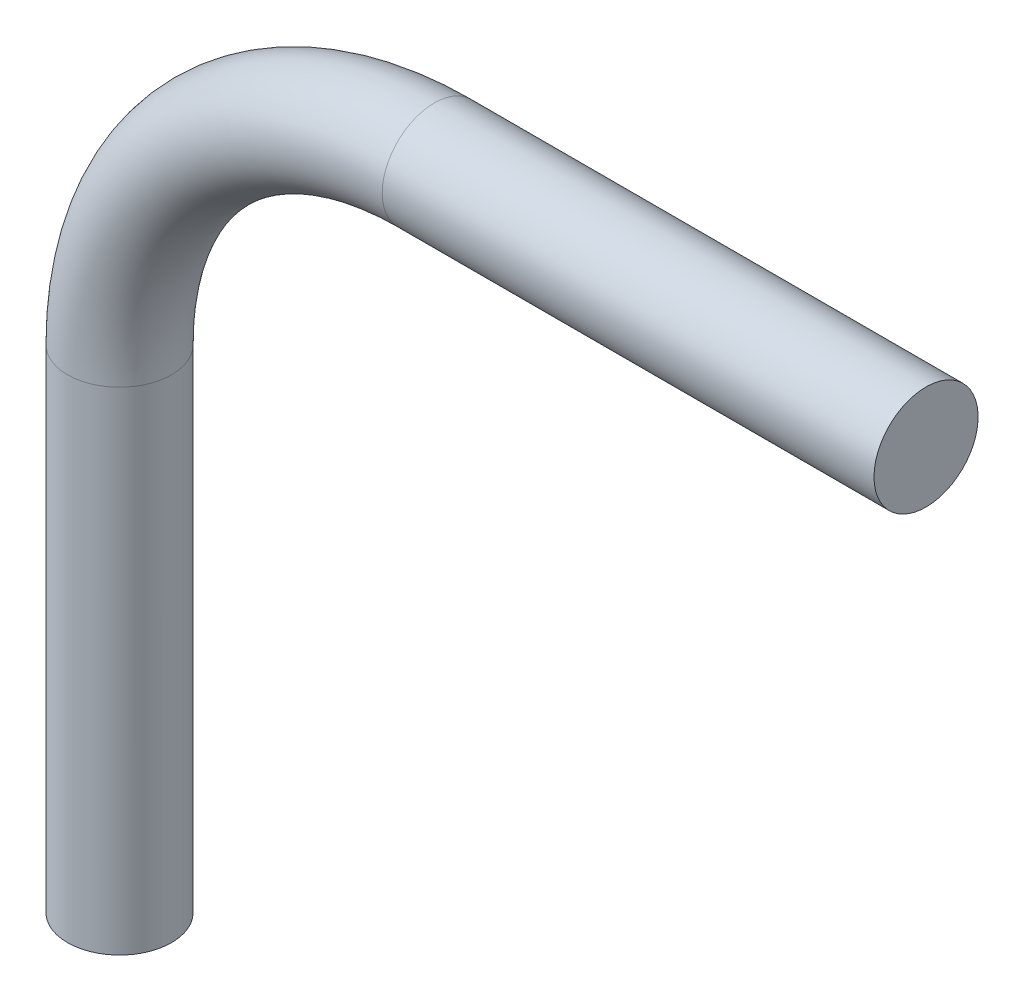
from build123d import *

# Parameters (mm, degrees)
BALAYAGE1_PROFILE_R = 3.175


with BuildPart() as part:
    # Balayage1: sweep along a path in Esquisse1
    with BuildLine(Plane.XY) as balayage1_path:
        Line((30, 19.2), (0, 19.2))
        ThreePointArc((0, 19.2), (-13.576450199, 13.576450199), (-19.2, 0))
        Line((-19.2, 0), (-19.2, -30))
    # Balayage1 profile (on start of the path) → Balayage1 (sweep)
    with BuildSketch(Plane(origin=(30, 19.2, 0), x_dir=(0, 0, -1), z_dir=(-1, 0, 0))):
        Circle(BALAYAGE1_PROFILE_R)
    sweep(path=balayage1_path.line)


solid = part.part
